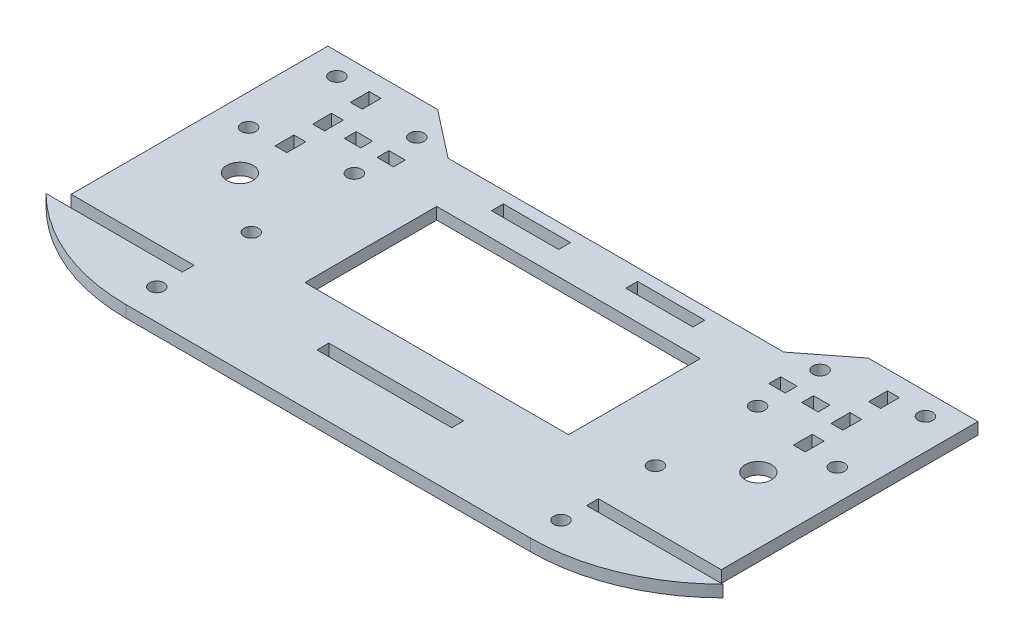
from build123d import *

# Parameters (mm, degrees)
SKETCH1_R           = 1.65
SKETCH1_R_2         = 3
SKETCH1_W           = 30.68
SKETCH1_H           = 2.7
SKETCH1_W_2         = 15.28
SKETCH1_W_3         = 2.7
SKETCH1_H_2         = 4.285714286
SKETCH1_W_4         = 3.73
SKETCH1_W_5         = 60
SKETCH1_H_3         = 30
BOSS_EXTRUDE1_DEPTH = 2.7


with BuildPart() as part:
    # Sketch1 → Boss-Extrude1 (new body)
    with BuildSketch(Plane(origin=(0, 0, 0), x_dir=(1, 0, 0), z_dir=(0, 1, 0))):
        with BuildLine():
            Line((-46, 0), (46, 0))
            ThreePointArc((46, 0), (62.780941571, 3.32568378), (77.025151087, 12.8))
            Line((77.025151087, 12.8), (46.015151087, 12.8))
            Line((46.015151087, 12.8), (46.015151087, 15.5))
            Line((46.015151087, 15.5), (73.995151087, 15.5))
            Line((73.995151087, 15.5), (73.995151087, 35.5))
            Line((73.995151087, 35.5), (73.995151087, 43.92))
            Line((73.995151087, 43.92), (73.995151087, 73.92))
            Line((73.995151087, 73.92), (68.995151087, 73.92))
            Line((68.995151087, 73.92), (48.995151087, 73.92))
            Line((48.995151087, 73.92), (38.2, 65.5))
            Line((38.2, 65.5), (-38.2, 65.5))
            Line((-38.2, 65.5), (-48.995151087, 73.92))
            Line((-48.995151087, 73.92), (-68.995151087, 73.92))
            Line((-68.995151087, 73.92), (-73.995151087, 73.92))
            Line((-73.995151087, 73.92), (-73.995151087, 15.5))
            Line((-73.995151087, 15.5), (-46.015151087, 15.5))
            Line((-46.015151087, 15.5), (-46.015151087, 12.8))
            Line((-46.015151087, 12.8), (-77.025151087, 12.8))
            ThreePointArc((-77.025151087, 12.8), (-62.780941571, 3.32568378), (-46, 0))
        make_face()
        with Locations((46, 28.5)):
            Circle(SKETCH1_R, mode=Mode.SUBTRACT)
        with Locations((46, 7)):
            Circle(SKETCH1_R, mode=Mode.SUBTRACT)
        with Locations((-46, 7)):
            Circle(SKETCH1_R, mode=Mode.SUBTRACT)
        with Locations((-46, 28.5)):
            Circle(SKETCH1_R, mode=Mode.SUBTRACT)
        with Locations((66.995151087, 68.959972417)):
            Circle(SKETCH1_R, mode=Mode.SUBTRACT)
        with Locations((66.995151087, 48.880027583)):
            Circle(SKETCH1_R, mode=Mode.SUBTRACT)
        with Locations((45.892266276, 66.076819007)):
            Circle(SKETCH1_R, mode=Mode.SUBTRACT)
        with Locations((45.892266276, 51.843125828)):
            Circle(SKETCH1_R, mode=Mode.SUBTRACT)
        with Locations((-66.995151087, 48.880027583)):
            Circle(SKETCH1_R, mode=Mode.SUBTRACT)
        with Locations((-45.892266276, 66.076819007)):
            Circle(SKETCH1_R, mode=Mode.SUBTRACT)
        with Locations((-66.995151087, 68.959972417)):
            Circle(SKETCH1_R, mode=Mode.SUBTRACT)
        with Locations((-45.892266276, 51.843125828)):
            Circle(SKETCH1_R, mode=Mode.SUBTRACT)
        with Locations((-58.995151087, 38.92)):
            Circle(SKETCH1_R_2, mode=Mode.SUBTRACT)
        with Locations((58.995151087, 38.92)):
            Circle(SKETCH1_R_2, mode=Mode.SUBTRACT)
        with Locations((0, 14.15)):
            Rectangle(SKETCH1_W, SKETCH1_H, mode=Mode.SUBTRACT)
        with Locations((-15.28, 61.45)):
            Rectangle(SKETCH1_W_2, SKETCH1_H, mode=Mode.SUBTRACT)
        with Locations((15.28, 61.45)):
            Rectangle(SKETCH1_W_2, SKETCH1_H, mode=Mode.SUBTRACT)
        with Locations((58.995151087, 58.959972417)):
            Rectangle(SKETCH1_W_3, SKETCH1_H_2, mode=Mode.SUBTRACT)
        with Locations((44.590151087, 58.927994483)):
            Rectangle(SKETCH1_W_4, SKETCH1_H, mode=Mode.SUBTRACT)
        with Locations((58.995151087, 50.388543846)):
            Rectangle(SKETCH1_W_3, SKETCH1_H_2, mode=Mode.SUBTRACT)
        with Locations((58.995151087, 67.531400989)):
            Rectangle(SKETCH1_W_3, SKETCH1_H_2, mode=Mode.SUBTRACT)
        with Locations((52.050151087, 58.94398345)):
            Rectangle(SKETCH1_W_4, SKETCH1_H, mode=Mode.SUBTRACT)
        with Locations((-52.050151087, 58.94398345)):
            Rectangle(SKETCH1_W_4, SKETCH1_H, mode=Mode.SUBTRACT)
        with Locations((-44.590151087, 58.927994483)):
            Rectangle(SKETCH1_W_4, SKETCH1_H, mode=Mode.SUBTRACT)
        with Locations((-58.995151087, 67.531400989)):
            Rectangle(SKETCH1_W_3, SKETCH1_H_2, mode=Mode.SUBTRACT)
        with Locations((-58.995151087, 58.959972417)):
            Rectangle(SKETCH1_W_3, SKETCH1_H_2, mode=Mode.SUBTRACT)
        with Locations((-58.995151087, 50.388543846)):
            Rectangle(SKETCH1_W_3, SKETCH1_H_2, mode=Mode.SUBTRACT)
        with Locations((0, 39.71)):
            Rectangle(SKETCH1_W_5, SKETCH1_H_3, mode=Mode.SUBTRACT)
    extrude(amount=BOSS_EXTRUDE1_DEPTH)


solid = part.part
